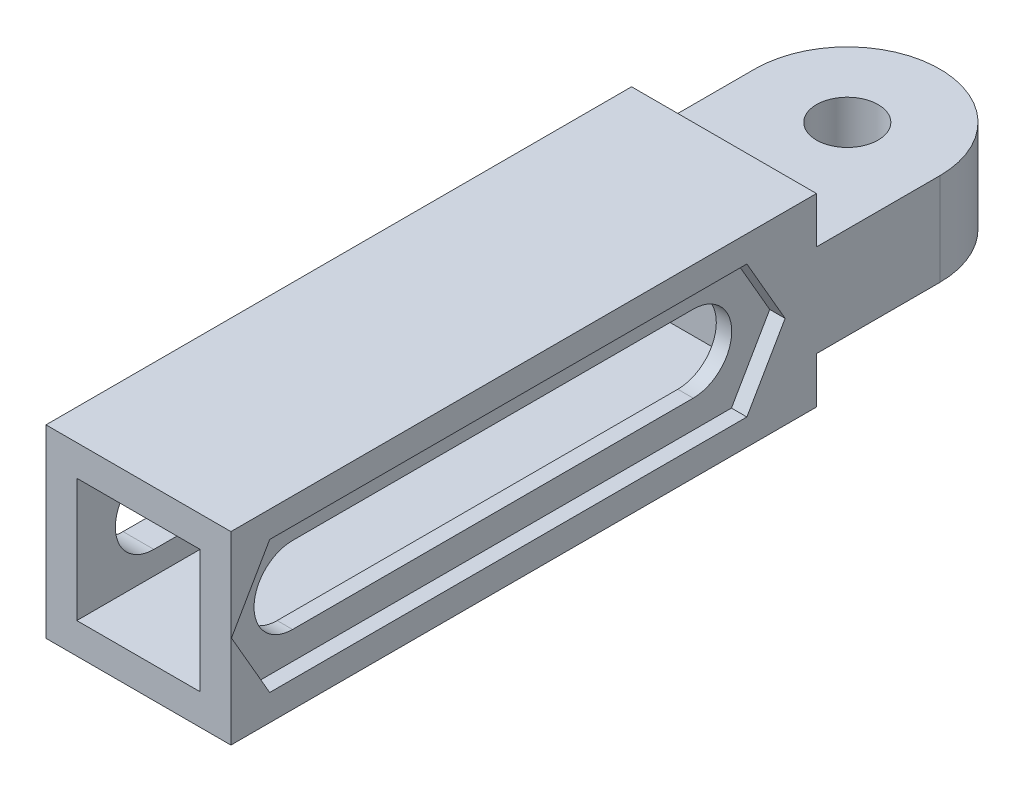
from build123d import *

# Parameters (mm, degrees)
SKETCH_1_W           = 6
SKETCH_1_H           = 6
SKETCH_1_W_2         = 4
SKETCH_1_H_2         = 4
EXTRUDE_1_DEPTH      = 18
SKETCH_2_W           = 6
SKETCH_2_H           = 6
EXTRUDE_2_DEPTH      = 1
SKETCH_3_R           = 1
EXTRUDE_3_DEPTH      = 1.5
EXTRUDE_3_DEPTH_BACK = 1.5
CUT_EXTRUDE_1_DEPTH  = 6
CUT_EXTRUDE_2_DEPTH  = 0.5


with BuildPart() as part:
    # 스케치1 → 보스-돌출1 (new body)
    with BuildSketch(Plane.XY):
        Rectangle(SKETCH_1_W, SKETCH_1_H)
        Rectangle(SKETCH_1_W_2, SKETCH_1_H_2, mode=Mode.SUBTRACT)
    extrude(amount=EXTRUDE_1_DEPTH)

    # 스케치2 → 보스-돌출2 (add)
    with BuildSketch(Plane(origin=(0, 0, 0), x_dir=(-1, 0, 0), z_dir=(0, 0, -1))):
        Rectangle(SKETCH_2_W, SKETCH_2_H)
    extrude(amount=EXTRUDE_2_DEPTH)

    # 스케치3 → 보스-돌출3 (add, two sides)
    with BuildSketch(Plane(origin=(0, 0, 0), x_dir=(1, 0, 0), z_dir=(0, 1, 0))) as extrude_3_sk:
        with BuildLine():
            Line((3, 5), (3, 1))
            Line((3, 1), (-3, 1))
            Line((-3, 1), (-3, 5))
            ThreePointArc((-3, 5), (0, 8), (3, 5))
        make_face()
        with Locations((0, 5)):
            Circle(SKETCH_3_R, mode=Mode.SUBTRACT)
    extrude(amount=EXTRUDE_3_DEPTH)
    extrude(extrude_3_sk.sketch, amount=-EXTRUDE_3_DEPTH_BACK)

    # 스케치4 → 컷-돌출1 (cut)
    with BuildSketch(Plane.ZY.offset(3)):
        with BuildLine():
            Line((15.5, 1.25), (2.5, 1.25))
            ThreePointArc((2.5, 1.25), (1.25, 0), (2.5, -1.25))
            Line((2.5, -1.25), (15.5, -1.25))
            ThreePointArc((15.5, -1.25), (16.75, 0), (15.5, 1.25))
        make_face()
    extrude(amount=-CUT_EXTRUDE_1_DEPTH, mode=Mode.SUBTRACT)

    # 스케치5 → 컷-돌출2 (cut)
    with BuildSketch(Plane(origin=(3, 0, 0), x_dir=(0, 0, -1), z_dir=(1, 0, 0))):
        Polygon((-9, 2.15), (-16.741303079, 2.15), (-17.982606158, 0), (-16.741303079, -2.15), (-9, -2.15), (-1.258696921, -2.15), (-0.017393842, 0), (-1.258696921, 2.15), align=None)
    extrude(amount=-CUT_EXTRUDE_2_DEPTH, mode=Mode.SUBTRACT)


solid = part.part
